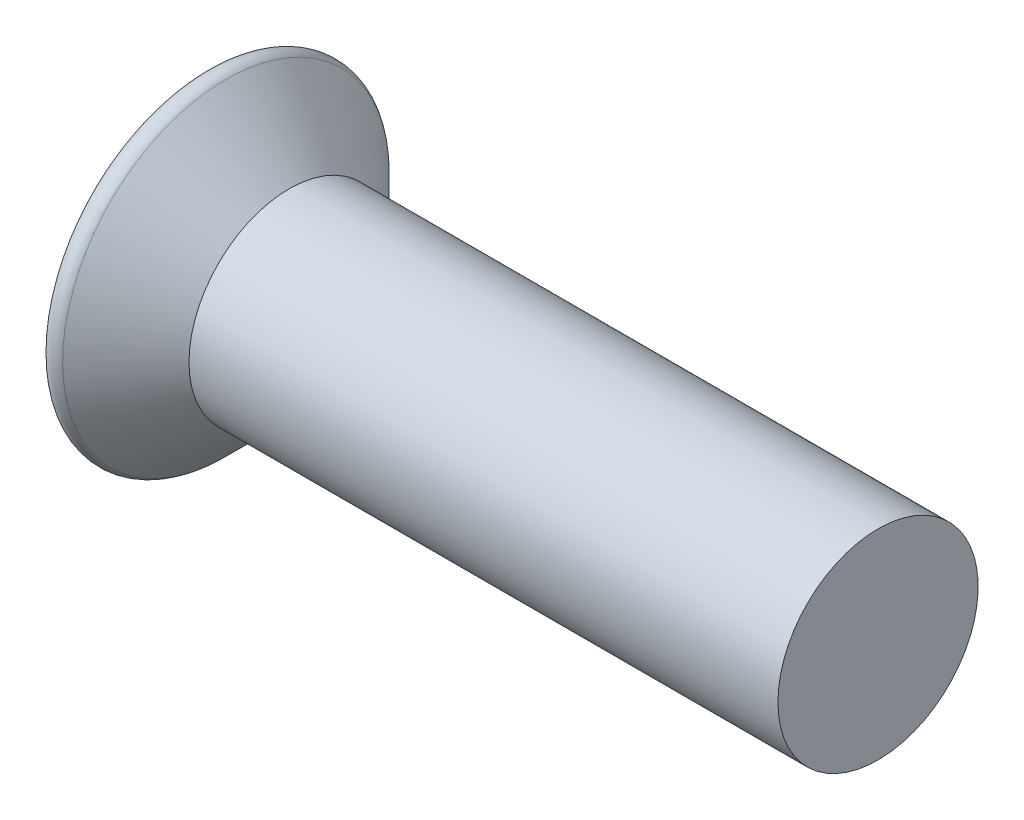
from build123d import *

# Parameters (mm, degrees)
SKETCH_2_W          = 0.232618696
SKETCH_2_H          = 0.868598709
SKETCH_2_W_2        = 0.868598709
SKETCH_2_H_2        = 0.232618696
CUT_EXTRUDE_1_DEPTH = 0.2
FILLET_1_R          = 0.1


with BuildPart() as part:
    # 草图1 → 旋转2 (revolve)
    with BuildSketch(Plane.XY):
        Polygon((-0.707106781, 0), (5, 0), (5, 0.85), (0, 0.85), (-0.707106781, 1.557106781), align=None)
    revolve(axis=Axis((-0.707106781, 0, 0), (1, 0, 0)))

    # 草图2 → 切除-拉伸1 (cut)
    with BuildSketch(Plane.ZY.offset(0.707106781)):
        with Locations((0, -0.550608703)):
            Rectangle(SKETCH_2_W, SKETCH_2_H)
        with Locations((0.550608703, 0)):
            Rectangle(SKETCH_2_W_2, SKETCH_2_H_2)
        Rectangle(SKETCH_2_W, SKETCH_2_H_2)
        with Locations((0, 0.550608703)):
            Rectangle(SKETCH_2_W, SKETCH_2_H)
        with Locations((-0.550608703, 0)):
            Rectangle(SKETCH_2_W_2, SKETCH_2_H_2)
    extrude(amount=-CUT_EXTRUDE_1_DEPTH, mode=Mode.SUBTRACT)

    # 圆角1
    fillet_1_edges = [part.edges().sort_by_distance(p)[0] for p in [
        (-0.707106781, -1.557106781, 0),
    ]]
    fillet(fillet_1_edges, radius=FILLET_1_R)


solid = part.part
